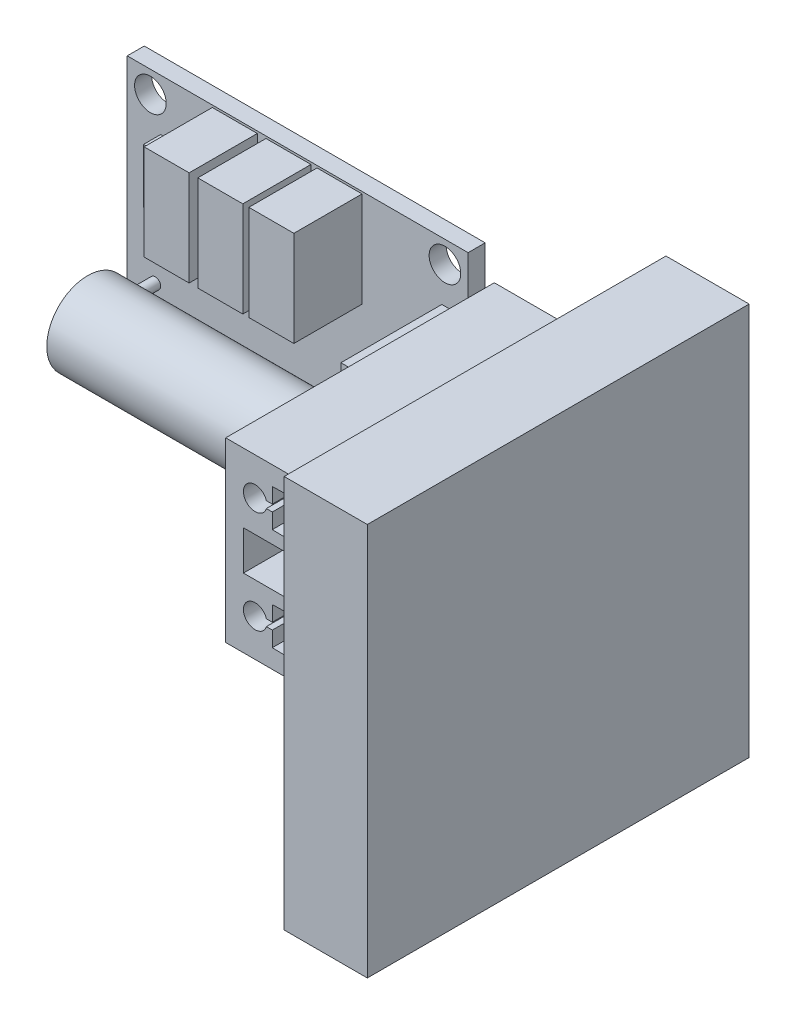
from build123d import *

# Parameters (mm, degrees)
SKETCH1_W                       = 31.75
SKETCH1_H                       = 22.098
BOSS_EXTRUDE1_DEPTH             = 1.5875
F_32_0_116_DIAMETER_HOLE1_D     = 2.9464
F_32_0_116_DIAMETER_HOLE1_DEPTH = 25.4
F_32_0_116_DIAMETER_HOLE1_TIP   = 0.885187864
SKETCH4_W                       = 4.191
SKETCH4_H                       = 8.89
BOSS_EXTRUDE2_DEPTH             = 6.35
SKETCH4_3_W                     = 2.466272753
SKETCH4_3_H                     = 5.065857547
BOSS_EXTRUDE3_DEPTH             = 1.5875
SKETCH4_4_R                     = 0.508
BOSS_EXTRUDE4_DEPTH             = 6.35
BOSS_EXTRUDE5_DEPTH             = 9.398
BOSS_EXTRUDE5_DEPTH_BACK        = 13.208
SKETCH5_R                       = 3.81
SKETCH6_W                       = 3.302
SKETCH6_H                       = 11.289974084
BOSS_EXTRUDE6_DEPTH             = 9.398
SKETCH8_W                       = 25.019
SKETCH8_H                       = 16.51
BOSS_EXTRUDE7_DEPTH             = 15.875
SKETCH9_W                       = 14.224
SKETCH9_H                       = 3.6576
CUT_EXTRUDE1_DEPTH              = 43.555420887
SKETCH10_W                      = 35.562788841
SKETCH10_H                      = 36.580807606
BOSS_EXTRUDE8_DEPTH             = 7.747


with BuildPart() as part:
    # Sketch1 → Boss-Extrude1 (new body)
    with BuildSketch(Plane.XY):
        Rectangle(SKETCH1_W, SKETCH1_H)
    extrude(amount=-BOSS_EXTRUDE1_DEPTH)

    # 32 _0.116_ Diameter Hole1
    with Locations(Plane.XY):
        with Locations((-13.716, 9.017), (13.716, -9.017), (13.716, 9.017), (-13.716, -9.017)):
            Hole(F_32_0_116_DIAMETER_HOLE1_D / 2, depth=F_32_0_116_DIAMETER_HOLE1_DEPTH)
            with Locations((0, 0, -(F_32_0_116_DIAMETER_HOLE1_DEPTH + F_32_0_116_DIAMETER_HOLE1_TIP / 2))):  # 118° drill point
                Cone(0, F_32_0_116_DIAMETER_HOLE1_D / 2, F_32_0_116_DIAMETER_HOLE1_TIP, mode=Mode.SUBTRACT)

    # Sketch4 → Boss-Extrude2 (add)
    with BuildSketch(Plane.XY):
        with Locations((-0.857280044, 6.398532258)):
            Rectangle(SKETCH4_W, SKETCH4_H)
        with Locations((-5.853947096, 6.4008)):
            Rectangle(SKETCH4_W, SKETCH4_H)
        with Locations((3.90076693, 6.4008)):
            Rectangle(SKETCH4_W, SKETCH4_H)
    extrude(amount=BOSS_EXTRUDE2_DEPTH)

    # Sketch4_3 → Boss-Extrude3 (add)
    with BuildSketch(Plane.XY):
        with Locations((-11.531344325, 3.722546838)):
            Rectangle(SKETCH4_3_W, SKETCH4_3_H)
    extrude(amount=BOSS_EXTRUDE3_DEPTH)

    # Sketch4_4 → Boss-Extrude4 (add)
    with BuildSketch(Plane.XY):
        with Locations((9.592700785, -5.979435424)):
            Circle(SKETCH4_4_R)
        with Locations((-13.267299215, -5.979435424)):
            Circle(SKETCH4_4_R)
    extrude(amount=BOSS_EXTRUDE4_DEPTH)

    # Sketch5 → Boss-Extrude5 (add, two sides: drawn at the far end of the back side and taken through both)
    with BuildSketch(Plane(origin=(0, 0, 0), x_dir=(0, 0, -1), z_dir=(1, 0, 0)).offset(-BOSS_EXTRUDE5_DEPTH_BACK)):
        with Locations((-6.35, -5.979435424)):
            Circle(SKETCH5_R)
    extrude(amount=BOSS_EXTRUDE5_DEPTH + BOSS_EXTRUDE5_DEPTH_BACK)

    # Sketch6 → Boss-Extrude6 (add)
    with BuildSketch(Plane.XY):
        with Locations((15.076654567, 0)):
            Rectangle(SKETCH6_W, SKETCH6_H)
    extrude(amount=BOSS_EXTRUDE6_DEPTH)

    # Sketch8 → Boss-Extrude7 (add)
    with BuildSketch(Plane(origin=(16.727654567, 0, 0), x_dir=(0, 0, -1), z_dir=(1, 0, 0))):
        with Locations((-10.922, 0)):
            Rectangle(SKETCH8_W, SKETCH8_H)
    extrude(amount=BOSS_EXTRUDE7_DEPTH)

    # Sketch9 → Cut-Extrude1 (cut, through all)
    with BuildSketch(Plane.XY.offset(23.4315)):
        with BuildLine():
            Line((21.071054567, 3.0226), (32.602654567, 2.794))
            Line((32.602654567, 2.794), (32.602654567, 6.731))
            Line((32.602654567, 6.731), (21.071054567, 6.5024))
            Line((21.071054567, 6.5024), (21.071054567, 5.08))
            Line((21.071054567, 5.08), (20.515887863, 5.08))
            ThreePointArc((20.515887863, 5.08), (18.378654567, 4.7625), (20.515887863, 4.445))
            Line((20.515887863, 4.445), (21.071054567, 4.445))
            Line((21.071054567, 4.445), (21.071054567, 3.0226))
        make_face()
        with BuildLine():
            Line((32.602654567, -6.731), (32.602654567, -2.794))
            Line((32.602654567, -2.794), (21.071054567, -3.0226))
            Line((21.071054567, -3.0226), (21.071054567, -4.445))
            Line((21.071054567, -4.445), (20.515887863, -4.445))
            ThreePointArc((20.515887863, -4.445), (18.378654567, -4.7625), (20.515887863, -5.08))
            Line((20.515887863, -5.08), (21.071054567, -5.08))
            Line((21.071054567, -5.08), (21.071054567, -6.5024))
            Line((21.071054567, -6.5024), (32.602654567, -6.731))
        make_face()
        with Locations((25.490654567, 0)):
            Rectangle(SKETCH9_W, SKETCH9_H)
    extrude(amount=-CUT_EXTRUDE1_DEPTH, mode=Mode.SUBTRACT)

    # Sketch10 → Boss-Extrude8 (add)
    with BuildSketch(Plane(origin=(32.602654567, 0, 0), x_dir=(0, 0, -1), z_dir=(1, 0, 0))):
        with Locations((-16.07996174, 0)):
            Rectangle(SKETCH10_W, SKETCH10_H)
    extrude(amount=BOSS_EXTRUDE8_DEPTH)


solid = part.part
